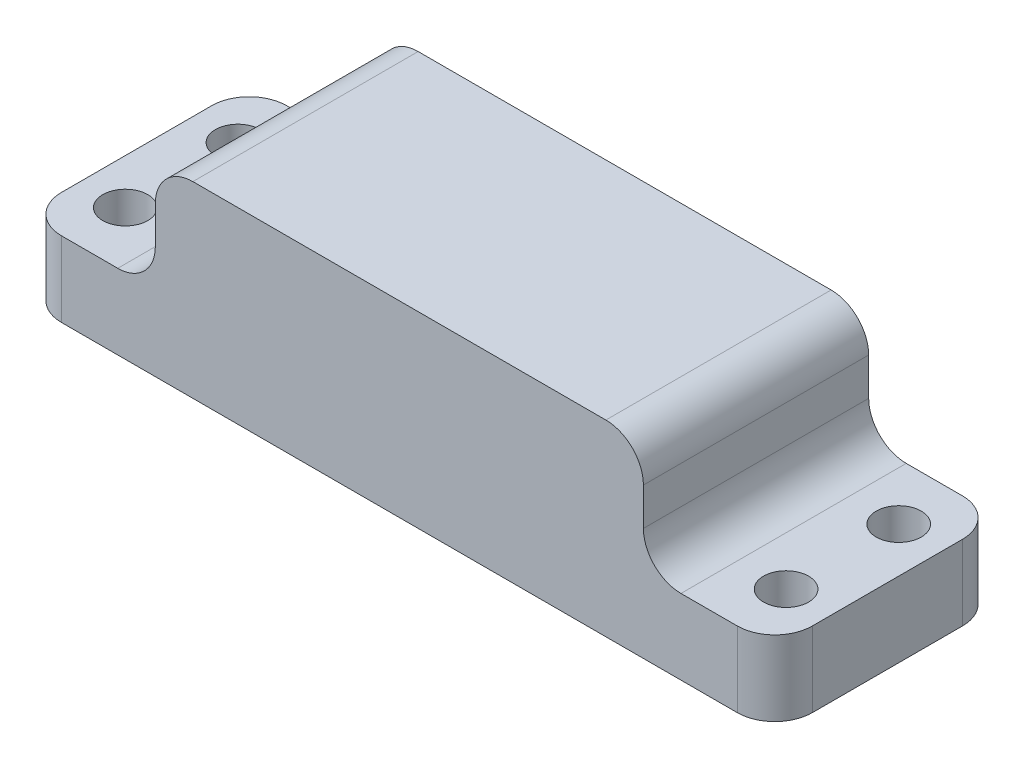
from build123d import *

# Parameters (mm, degrees)
BOSS_EXTRUDE1_DEPTH                     = 60
FILLET1_R                               = 10
CBORE_FOR_M5_HEX_HEAD_BOLT1_D           = 8
CBORE_FOR_M5_HEX_HEAD_BOLT1_CBORE_D     = 12
CBORE_FOR_M5_HEX_HEAD_BOLT1_CBORE_DEPTH = 10


with BuildPart() as part:
    # Sketch1 → Boss-Extrude1 (new body)
    with BuildSketch(Plane.XY):
        with BuildLine():
            Line((-67.372881356, 64.576271186), (42.627118644, 64.576271186))
            ThreePointArc((42.627118644, 64.576271186), (49.698186456, 61.647338998), (52.627118644, 54.576271186))
            Line((52.627118644, 54.576271186), (52.627118644, 44.576271186))
            ThreePointArc((52.627118644, 44.576271186), (55.556050832, 37.505203375), (62.627118644, 34.576271186))
            Line((62.627118644, 34.576271186), (87.627118644, 34.576271186))
            Line((87.627118644, 34.576271186), (87.627118644, 14.576271186))
            Line((87.627118644, 14.576271186), (-112.372881356, 14.576271186))
            Line((-112.372881356, 14.576271186), (-112.372881356, 34.576271186))
            Line((-112.372881356, 34.576271186), (-87.372881356, 34.576271186))
            ThreePointArc((-87.372881356, 34.576271186), (-80.301813544, 37.505203375), (-77.372881356, 44.576271186))
            Line((-77.372881356, 44.576271186), (-77.372881356, 54.576271186))
            ThreePointArc((-77.372881356, 54.576271186), (-74.443949168, 61.647338998), (-67.372881356, 64.576271186))
        make_face()
    extrude(amount=BOSS_EXTRUDE1_DEPTH)

    # Fillet1
    fillet1_edges = [part.edges().sort_by_distance(p)[0] for p in [
        (87.627118644, 24.576271186, 0),
        (-112.372881356, 24.576271186, 0),
        (-112.372881356, 24.576271186, 60),
        (87.627118644, 24.576271186, 60),
    ]]
    fillet(fillet1_edges, radius=FILLET1_R)

    # CBORE for M5 Hex Head Bolt1 (through all)
    with Locations(Plane(origin=(0, 34.576271186, 0), x_dir=(1, 0, 0), z_dir=(0, 1, 0))):
        with Locations((-100.372881356, -15), (-100.372881356, -45), (75.627118644, -15), (75.627118644, -45)):
            CounterBoreHole(CBORE_FOR_M5_HEX_HEAD_BOLT1_D / 2, CBORE_FOR_M5_HEX_HEAD_BOLT1_CBORE_D / 2, CBORE_FOR_M5_HEX_HEAD_BOLT1_CBORE_DEPTH)


solid = part.part
